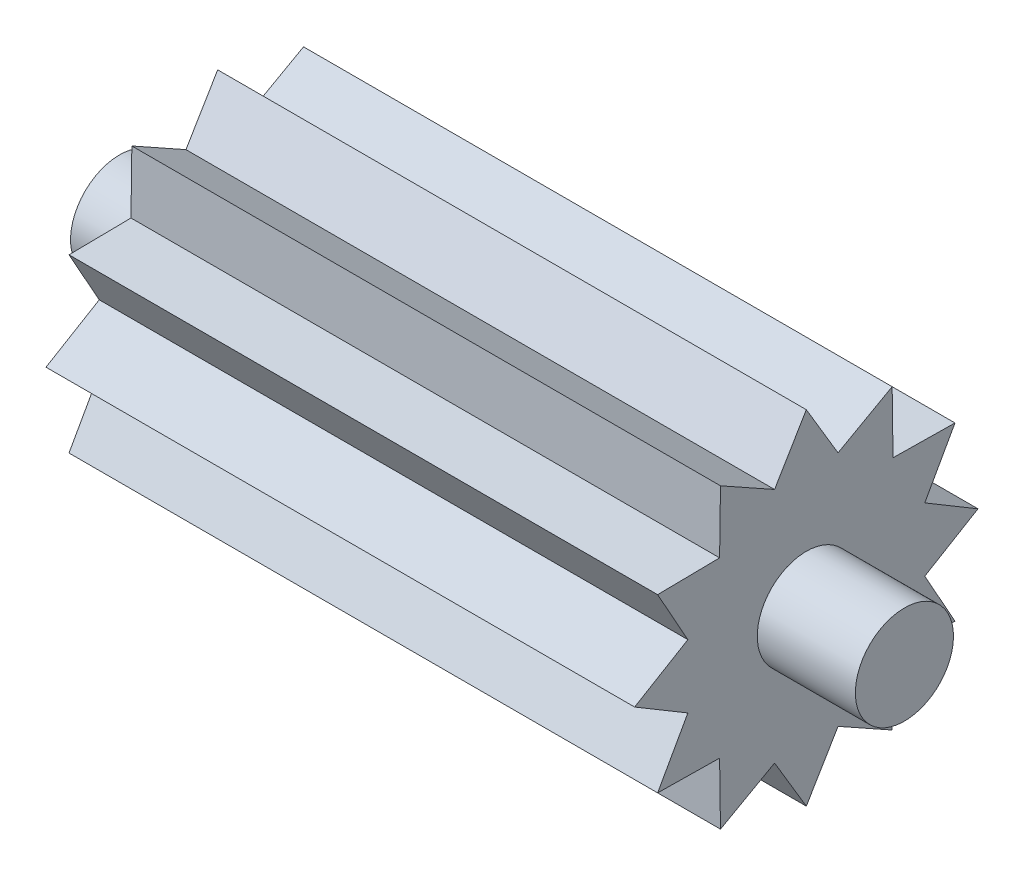
from build123d import *

# Parameters (mm, degrees)
BOSS_EXTRUDE1_DEPTH = 15
SKETCH4_R           = 2.5
BOSS_EXTRUDE3_DEPTH = 5


with BuildPart() as part:
    # Sketch1 → Boss-Extrude1 (new body)
    with BuildSketch(Plane(origin=(0, 0, 0), x_dir=(0, 0, -1), z_dir=(1, 0, 0))):
        Polygon((0, 8.75), (1.617619032, 6.037036414), (4.375, 7.577722283), (4.419417382, 4.419417382), (7.577722283, 4.375), (6.037036414, 1.617619032), (8.75, 0), (6.037036414, -1.617619032), (7.577722283, -4.375), (4.419417382, -4.419417382), (4.375, -7.577722283), (1.617619032, -6.037036414), (0, -8.75), (-1.617619032, -6.037036414), (-4.375, -7.577722283), (-4.419417382, -4.419417382), (-7.577722283, -4.375), (-6.037036414, -1.617619032), (-8.75, 0), (-6.037036414, 1.617619032), (-7.577722283, 4.375), (-4.419417382, 4.419417382), (-4.375, 7.577722283), (-1.617619032, 6.037036414), align=None)
    boss_extrude1 = extrude(amount=BOSS_EXTRUDE1_DEPTH)

    # Sketch4 → Boss-Extrude3 (add)
    with BuildSketch(Plane(origin=(15, 0, 0), x_dir=(0, 0, -1), z_dir=(1, 0, 0))):
        Circle(SKETCH4_R)
    boss_extrude3 = extrude(amount=BOSS_EXTRUDE3_DEPTH)

    # Mirror1: Boss-Extrude1, Boss-Extrude3 across plane
    add(boss_extrude1.mirror(Plane(origin=(0, 0, 0), x_dir=(0, 0, 1), z_dir=(1, 0, 0))))
    add(boss_extrude3.mirror(Plane(origin=(0, 0, 0), x_dir=(0, 0, 1), z_dir=(1, 0, 0))))


solid = part.part
